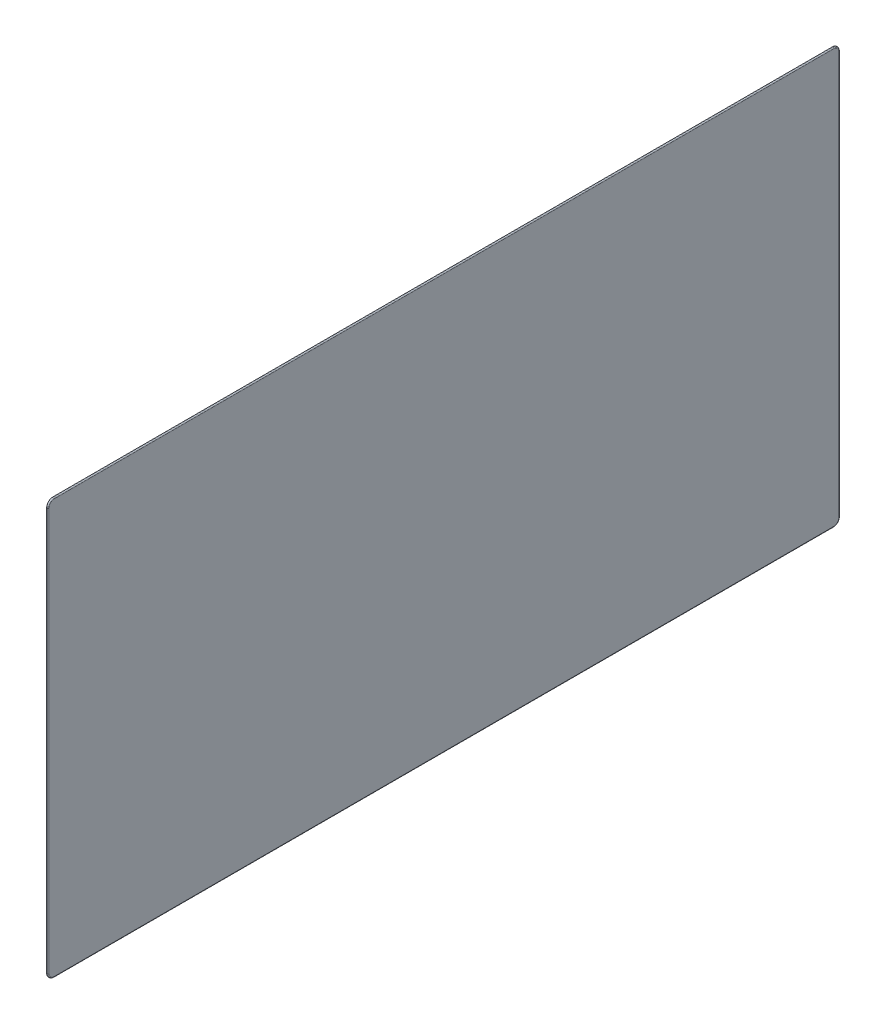
from build123d import *

# Parameters (mm, degrees)
BOSS_EXTRUDE1_DEPTH = 0.61
FILLET1_R           = 0.5


with BuildPart() as part:
    # Sketch1 → Boss-Extrude1 (new body)
    with BuildSketch(Plane(origin=(716.7, 0, 0), x_dir=(0, 0, -1), z_dir=(1, 0, 0))):
        with BuildLine():
            Line((185.218894284, 76), (185.218894284, 264.432))
            ThreePointArc((185.218894284, 264.432), (184.340214627, 266.553320344), (182.218894284, 267.432))
            Line((182.218894284, 267.432), (0, 267.432))
            Line((0, 267.432), (-182.218894284, 267.432))
            ThreePointArc((-182.218894284, 267.432), (-184.340214627, 266.553320344), (-185.218894284, 264.432))
            Line((-185.218894284, 264.432), (-185.218894284, 76))
            ThreePointArc((-185.218894284, 76), (-184.340214627, 73.878679656), (-182.218894284, 73))
            Line((-182.218894284, 73), (0, 73))
            Line((0, 73), (182.218894284, 73))
            ThreePointArc((182.218894284, 73), (184.340214627, 73.878679656), (185.218894284, 76))
        make_face()
    extrude(amount=BOSS_EXTRUDE1_DEPTH)

    # Fillet1
    fillet1_edges = [part.edges().sort_by_distance(p)[0] for p in [
        (717.31, 266.553320344, -184.340214627),
        (717.31, 267.432, 0),
        (717.31, 266.553320344, 184.340214627),
        (717.31, 170.216, 185.218894284),
        (717.31, 73.878679656, 184.340214627),
        (717.31, 73, 0),
        (717.31, 73.878679656, -184.340214627),
        (717.31, 170.216, -185.218894284),
    ]]
    fillet(fillet1_edges, radius=FILLET1_R)


solid = part.part
